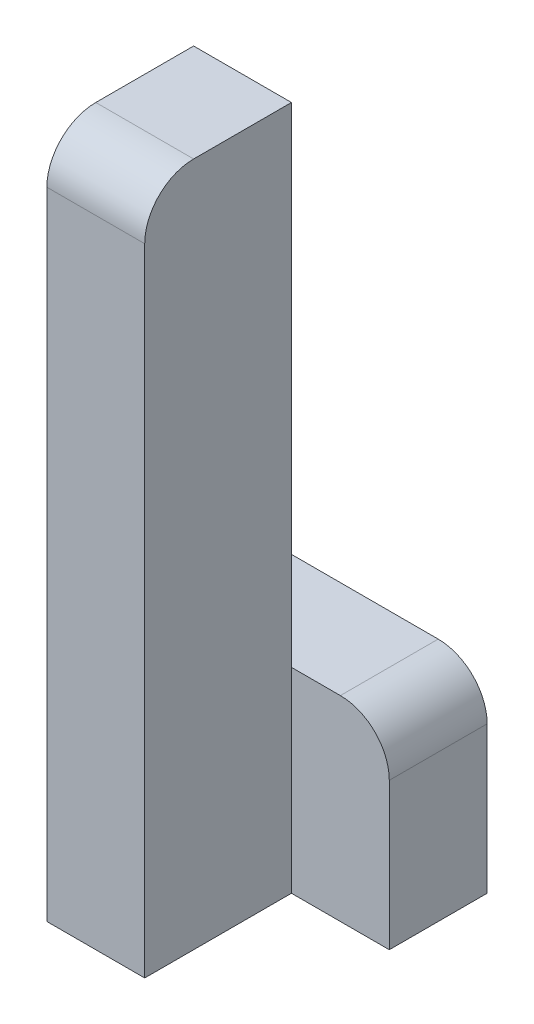
from build123d import *

# Parameters (mm, degrees)
SKETCH1_W           = 20
SKETCH1_H           = 140
BOSS_EXTRUDE1_DEPTH = 30
SKETCH2_W           = 40
SKETCH2_H           = 40
BOSS_EXTRUDE2_DEPTH = 20
FILLET1_R           = 10


with BuildPart() as part:
    # Sketch1 → Boss-Extrude1 (new body)
    with BuildSketch(Plane.XY):
        with Locations((-20, -70)):
            Rectangle(SKETCH1_W, SKETCH1_H)
    extrude(amount=BOSS_EXTRUDE1_DEPTH)

    # Sketch2 → Boss-Extrude2 (add)
    with BuildSketch(Plane.XY):
        with Locations((-10, -120)):
            Rectangle(SKETCH2_W, SKETCH2_H)
    extrude(amount=-BOSS_EXTRUDE2_DEPTH)

    # Fillet1
    fillet1_edges = [part.edges().sort_by_distance(p)[0] for p in [
        (10, -100, -10),
        (-20, 0, 30),
    ]]
    fillet(fillet1_edges, radius=FILLET1_R)


solid = part.part
